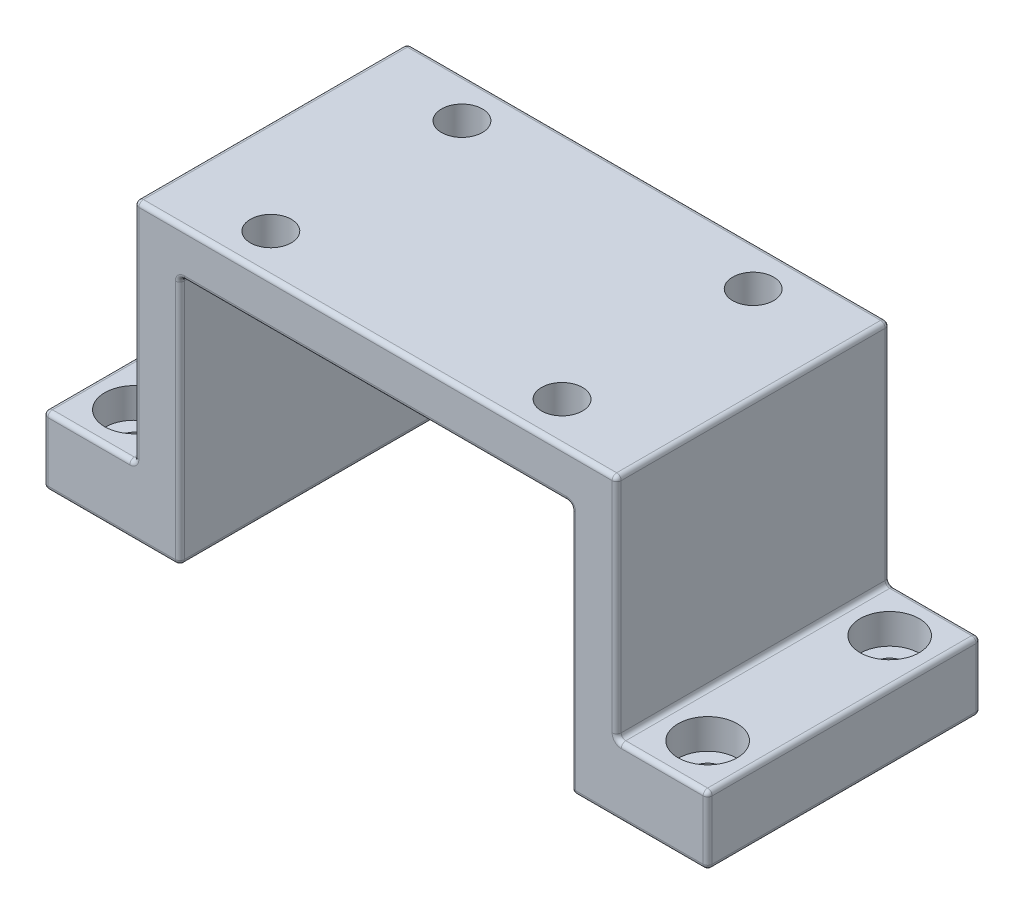
from build123d import *

# Parameters (mm, degrees)
SKETCH1_W           = 106
SKETCH1_H           = 60
BOSS_EXTRUDE1_DEPTH = 10
SKETCH2_W           = 10
SKETCH2_H           = 60
BOSS_EXTRUDE2_DEPTH = 55
SKETCH3_W           = 60
SKETCH3_H           = 15
BOSS_EXTRUDE3_DEPTH = 20
SKETCH4_W           = 60
SKETCH4_H           = 15
BOSS_EXTRUDE4_DEPTH = 20
SKETCH5_R           = 4.5
CUT_EXTRUDE1_DEPTH  = 66
SKETCH6_R           = 6.5
CUT_EXTRUDE2_DEPTH  = 6.6
SKETCH7_R           = 3.3
CUT_EXTRUDE3_DEPTH  = 9.4
FILLET1_R           = 1


with BuildPart() as part:
    # Sketch1 → Boss-Extrude1 (new body)
    with BuildSketch(Plane(origin=(0, 0, 0), x_dir=(1, 0, 0), z_dir=(0, 1, 0))):
        Rectangle(SKETCH1_W, SKETCH1_H)
    extrude(amount=BOSS_EXTRUDE1_DEPTH)

    # Sketch2 → Boss-Extrude2 (add)
    with BuildSketch(Plane.XZ):
        with Locations((-48, 0)):
            Rectangle(SKETCH2_W, SKETCH2_H)
        with Locations((48, 0)):
            Rectangle(SKETCH2_W, SKETCH2_H)
    extrude(amount=BOSS_EXTRUDE2_DEPTH)

    # Sketch3 → Boss-Extrude3 (add)
    with BuildSketch(Plane(origin=(53, 0, 0), x_dir=(0, 0, -1), z_dir=(1, 0, 0))):
        with Locations((0, -47.5)):
            Rectangle(SKETCH3_W, SKETCH3_H)
    extrude(amount=BOSS_EXTRUDE3_DEPTH)

    # Sketch4 → Boss-Extrude4 (add)
    with BuildSketch(Plane.ZY.offset(53)):
        with Locations((0, -47.5)):
            Rectangle(SKETCH4_W, SKETCH4_H)
    extrude(amount=BOSS_EXTRUDE4_DEPTH)

    # Sketch5 → Cut-Extrude1 (cut, through all)
    with BuildSketch(Plane(origin=(0, 10, 0), x_dir=(1, 0, 0), z_dir=(0, 1, 0))):
        with Locations((-32, 21)):
            Circle(SKETCH5_R)
        with Locations((32, 21)):
            Circle(SKETCH5_R)
        with Locations((32, -21)):
            Circle(SKETCH5_R)
        with Locations((-32, -21)):
            Circle(SKETCH5_R)
    extrude(amount=-CUT_EXTRUDE1_DEPTH, mode=Mode.SUBTRACT)

    # Sketch6 → Cut-Extrude2 (cut)
    with BuildSketch(Plane(origin=(0, -40, 0), x_dir=(1, 0, 0), z_dir=(0, 1, 0))):
        with Locations((63, 20)):
            Circle(SKETCH6_R)
        with Locations((63, -20)):
            Circle(SKETCH6_R)
        with Locations((-63, 20)):
            Circle(SKETCH6_R)
        with Locations((-63, -20)):
            Circle(SKETCH6_R)
    extrude(amount=-CUT_EXTRUDE2_DEPTH, mode=Mode.SUBTRACT)

    # Sketch7 → Cut-Extrude3 (cut, through all)
    with BuildSketch(Plane(origin=(0, -46.6, 0), x_dir=(1, 0, 0), z_dir=(0, 1, 0))):
        with Locations((-63, 20)):
            Circle(SKETCH7_R)
        with Locations((-63, -20)):
            Circle(SKETCH7_R)
        with Locations((63, -20)):
            Circle(SKETCH7_R)
        with Locations((63, 20)):
            Circle(SKETCH7_R)
    extrude(amount=-CUT_EXTRUDE3_DEPTH, mode=Mode.SUBTRACT)

    # Fillet1
    fillet1_edges = [part.edges().sort_by_distance(p)[0] for p in [
        (-53, 10, 0),
        (0, 0, 30),
        (-43, 0, 0),
        (-43, -27.5, -30),
        (-43, -27.5, 30),
        (-58, -55, -30),
        (0, 10, 30),
        (-43, -55, 0),
        (-58, -55, 30),
        (0, 0, -30),
        (43, 0, 0),
        (43, -27.5, 30),
        (43, -27.5, -30),
        (58, -55, 30),
        (43, -55, 0),
        (58, -55, -30),
        (63, -40, 30),
        (53, -40, 0),
        (63, -40, -30),
        (73, -47.5, 30),
        (73, -55, 0),
        (73, -47.5, -30),
        (73, -40, 0),
        (53, 10, 0),
        (-63, -40, -30),
        (-53, -40, 0),
        (-63, -40, 30),
        (-73, -47.5, -30),
        (-73, -55, 0),
        (-73, -47.5, 30),
        (-73, -40, 0),
        (53, -15, 30),
        (-53, -15, 30),
        (-53, -15, -30),
        (53, -15, -30),
        (0, 10, -30),
    ]]
    fillet(fillet1_edges, radius=FILLET1_R)


solid = part.part
